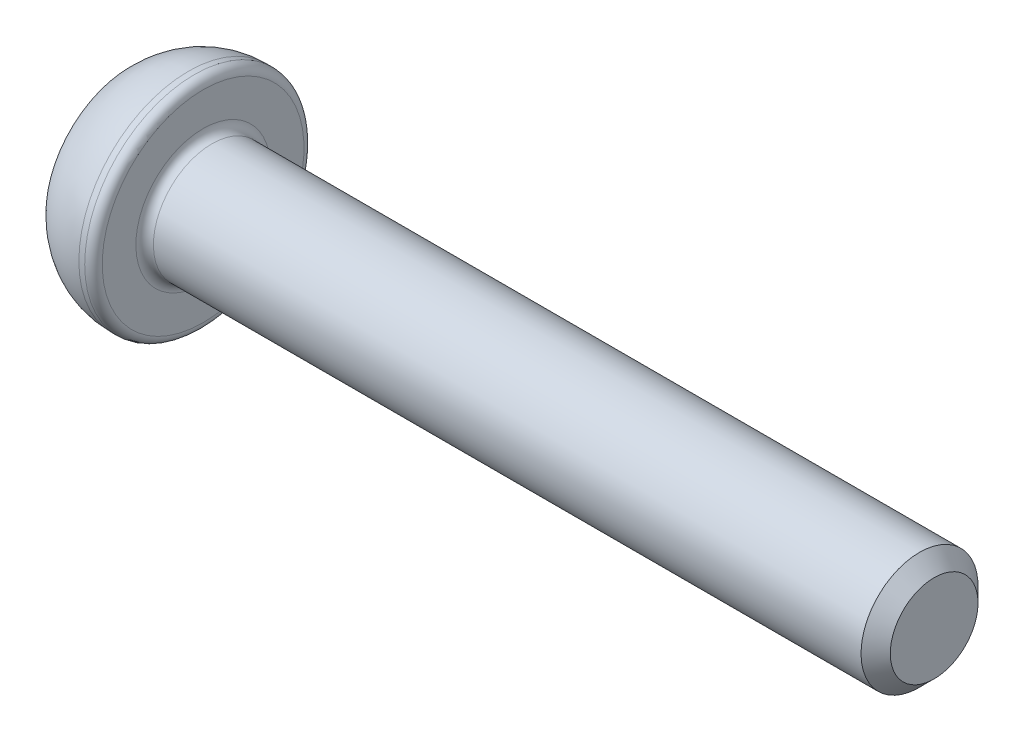
from build123d import *

# Parameters (mm, degrees)
CUT_EXTRUDE_1_DEPTH = 1.5
FILLET_1_R          = 0.3
CHAMFER_1_SIZE      = 0.5


with BuildPart() as part:
    # Эскиз1 → Повернуть1 (revolve)
    with BuildSketch(Plane.XY):
        with BuildLine():
            Line((0, 0), (0, 2.875))
            ThreePointArc((0, 2.875), (0.908484425, 3.521678457), (2, 3.75))
            Line((2, 3.75), (2.5, 3.75))
            Line((2.5, 3.75), (2.5, 2))
            Line((2.5, 2), (27.5, 2))
            Line((27.5, 2), (27.5, 0))
            Line((27.5, 0), (0, 0))
        make_face()
    revolve(axis=Axis((27.5, 0, 0), (-1, 0, 0)))

    # Эскиз2 → Вырез-Вытянуть1 (cut)
    with BuildSketch(Plane.ZY):
        Polygon((0.721687836, 1.25), (-0.721687836, 1.25), (-1.443375673, 0), (-0.721687836, -1.25), (0.721687836, -1.25), (1.443375673, 0), align=None)
    extrude(amount=-CUT_EXTRUDE_1_DEPTH, mode=Mode.SUBTRACT)

    # Скругление1
    fillet_1_edges = [part.edges().sort_by_distance(p)[0] for p in [
        (2.5, -2, 0),
        (2.5, -3.75, 0),
    ]]
    fillet(fillet_1_edges, radius=FILLET_1_R)

    # Фаска1
    chamfer_1_edges = [part.edges().sort_by_distance(p)[0] for p in [
        (27.5, -2, 0),
    ]]
    chamfer(chamfer_1_edges, length=CHAMFER_1_SIZE)


solid = part.part
